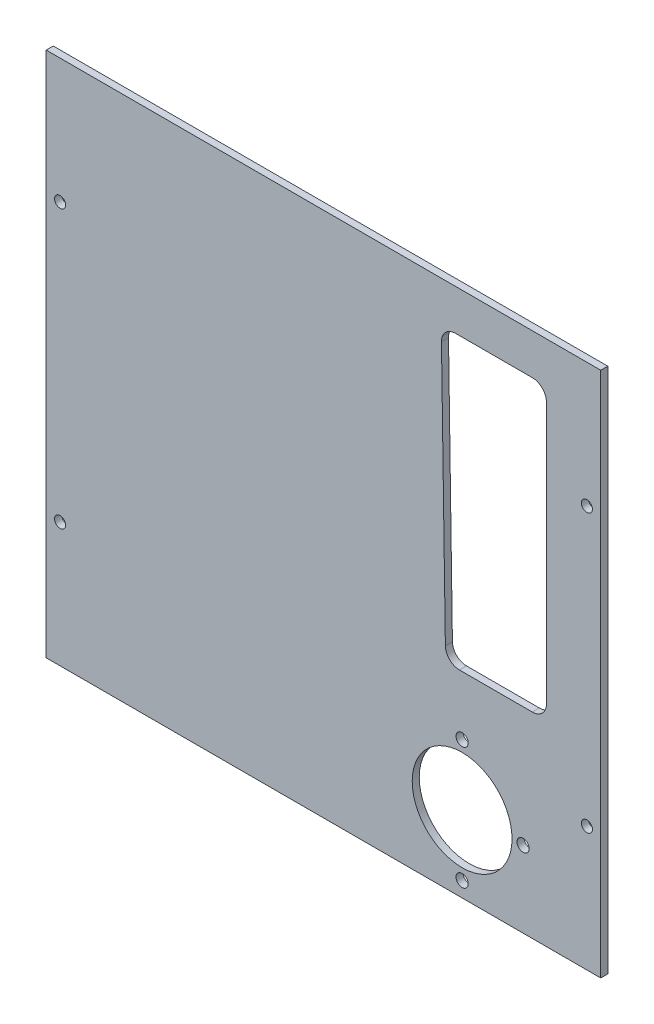
from build123d import *

# Parameters (mm, degrees)
SKETCH1_W           = 100
SKETCH1_H           = 94.92
BOSS_EXTRUDE1_DEPTH = 1.27
SKETCH14_R          = 9
SKETCH14_R_2        = 8
SKETCH14_R_3        = 6
SKETCH14_R_4        = 1.1
CUT_EXTRUDE8_DEPTH  = 5
SKETCH15_R          = 1
CUT_EXTRUDE9_DEPTH  = 10
CUT_EXTRUDE11_DEPTH = 2.54


with BuildPart() as part:
    # Sketch1 → Boss-Extrude1 (new body)
    with BuildSketch(Plane.XY):
        with Locations((50, 48.73)):
            Rectangle(SKETCH1_W, SKETCH1_H)
    extrude(amount=BOSS_EXTRUDE1_DEPTH)

    # Sketch14 → Cut-Extrude8 (cut)
    with BuildSketch(Plane(origin=(0, 0, 0), x_dir=(-1, 0, 0), z_dir=(0, 0, -1))):
        with Locations((-75, 15)):
            Circle(SKETCH14_R)
        with Locations((-75, 15)):
            Circle(SKETCH14_R_2, mode=Mode.SUBTRACT)
        with Locations((-75, 15)):
            Circle(SKETCH14_R_2)
        with Locations((-75, 15)):
            Circle(SKETCH14_R_3, mode=Mode.SUBTRACT)
        with Locations((-75, 15)):
            Circle(SKETCH14_R_3)
        with Locations((-75, 26)):
            Circle(SKETCH14_R_4)
        with Locations((-86, 15)):
            Circle(SKETCH14_R_4)
        with Locations((-75, 4)):
            Circle(SKETCH14_R_4)
    extrude(amount=-CUT_EXTRUDE8_DEPTH, mode=Mode.SUBTRACT)

    # Sketch15 → Cut-Extrude9 (cut)
    with BuildSketch(Plane(origin=(0, 0, 0), x_dir=(-1, 0, 0), z_dir=(0, 0, -1))):
        with Locations(Location((-2.5, 73.73, 0), (0, 0, 180))):
            Circle(SKETCH15_R)
        with Locations(Location((-2.5, 23.73, 0), (0, 0, 180))):
            Circle(SKETCH15_R)
        with Locations((-97.5, 23.73)):
            Circle(SKETCH15_R)
        with Locations((-97.5, 73.73)):
            Circle(SKETCH15_R)
    extrude(amount=-CUT_EXTRUDE9_DEPTH, mode=Mode.SUBTRACT)

    # Sketch18 → Cut-Extrude11 (cut)
    with BuildSketch(Plane.XY.offset(1.27)):
        with BuildLine():
            Line((87.669088652, 88.855847161), (73.816841533, 88.855847161))
            ThreePointArc((73.816841533, 88.855847161), (72.007429626, 88.098437566), (71.277124758, 86.277916888))
            Line((71.277124758, 86.277916888), (71.981132893, 39.139282942))
            ThreePointArc((71.981132893, 39.139282942), (72.738259262, 37.367801309), (74.520849667, 36.637213215))
            Line((74.520849667, 36.637213215), (87.669088652, 36.637213215))
            ThreePointArc((87.669088652, 36.637213215), (89.465139876, 37.381161991), (90.209088652, 39.177213215))
            Line((90.209088652, 39.177213215), (90.209088652, 86.315847161))
            ThreePointArc((90.209088652, 86.315847161), (89.465139876, 88.111898385), (87.669088652, 88.855847161))
        make_face()
    extrude(amount=-CUT_EXTRUDE11_DEPTH, mode=Mode.SUBTRACT)


solid = part.part
